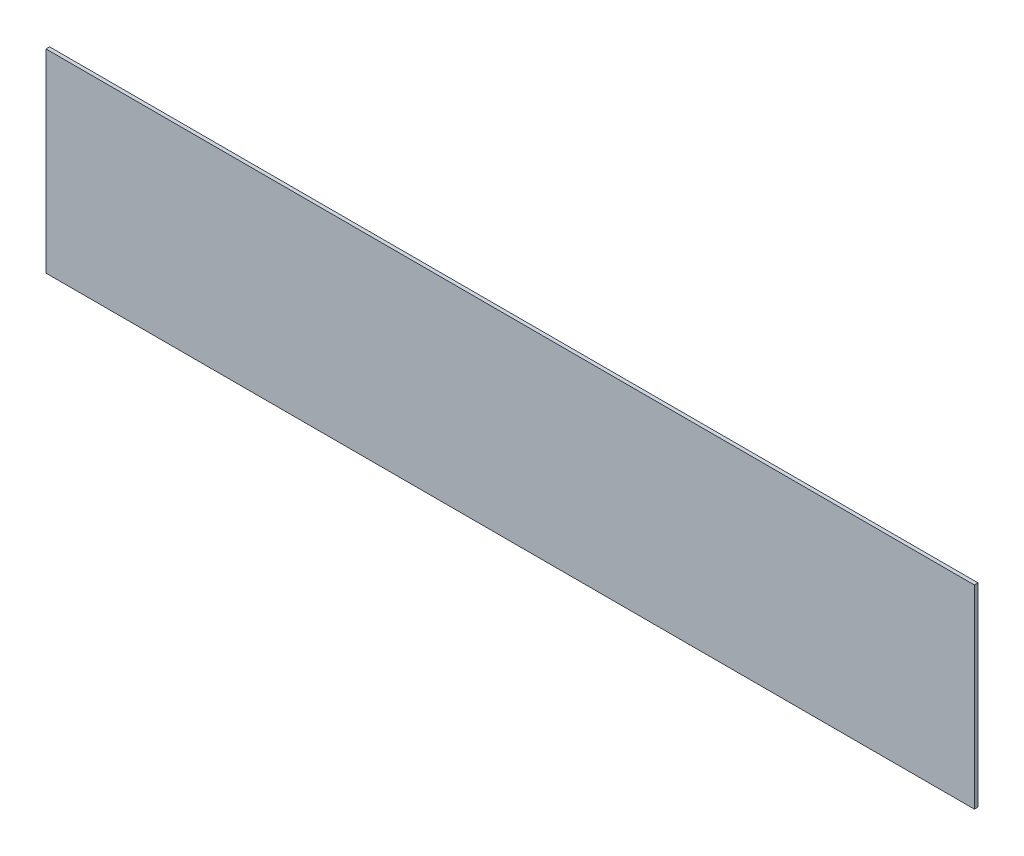
from build123d import *

# Parameters (mm, degrees)
SKETCH1_W           = 1214.4375
SKETCH1_H           = 254
BOSS_EXTRUDE1_DEPTH = 4.7625


with BuildPart() as part:
    # Sketch1 → Boss-Extrude1 (new body)
    with BuildSketch(Plane.XY):
        Rectangle(SKETCH1_W, SKETCH1_H)
    extrude(amount=BOSS_EXTRUDE1_DEPTH)


solid = part.part
